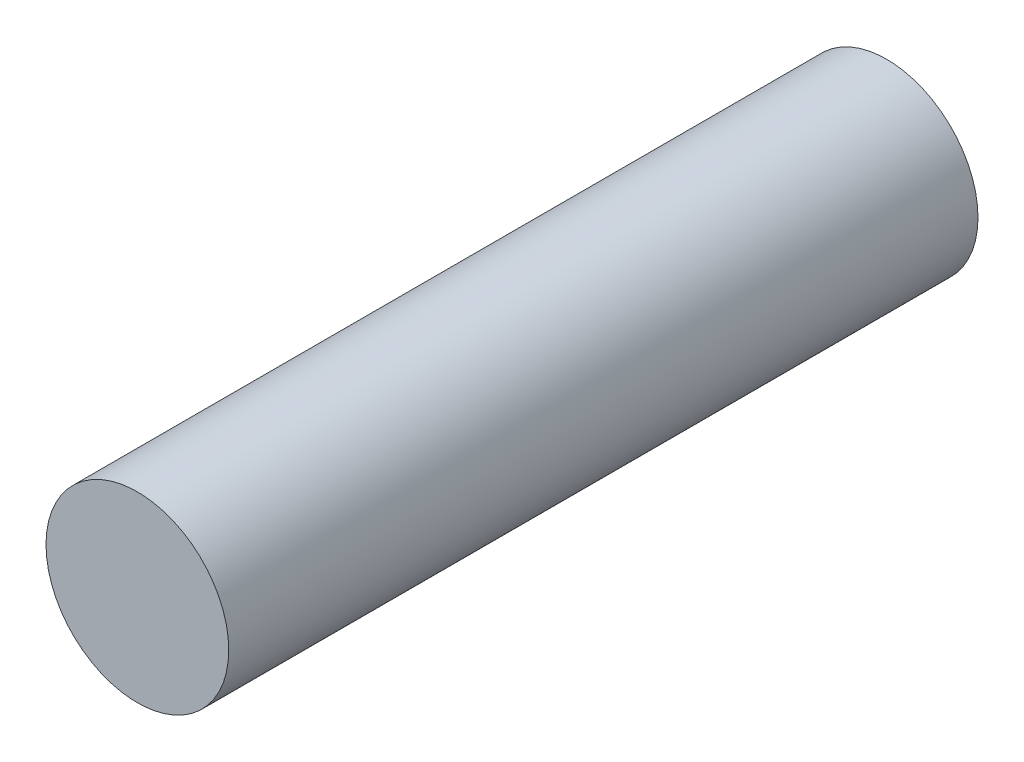
from build123d import *

# Parameters (mm, degrees)
SKETCH2_R = 2.5
SKETCH3_R = 2.5


with BuildPart() as part:
    # Sketch2 → Loft1 section 0
    with BuildSketch(Plane.XY):
        Circle(SKETCH2_R)
    # Sketch3 → Loft1 section 1
    with BuildSketch(Plane.XY.offset(20.5)):
        Circle(SKETCH3_R)
    loft()


solid = part.part
